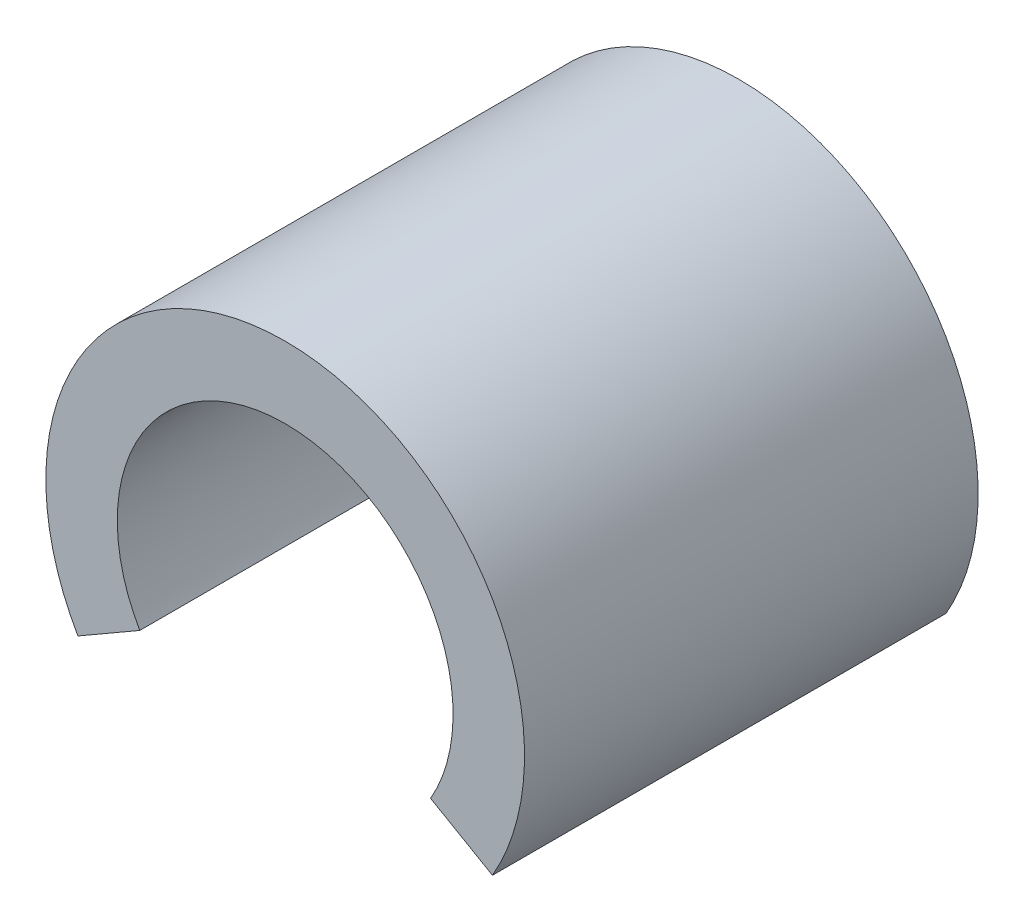
from build123d import *

# Parameters (mm, degrees)
BOSS_EXTRUDE1_DEPTH = 12.7


with BuildPart() as part:
    # Sketch1 → Boss-Extrude1 (new body)
    with BuildSketch(Plane.XY):
        with BuildLine():
            Line((-4.070319398, -2.35), (-5.802370205, -3.35))
            ThreePointArc((-5.802370205, -3.35), (0, 6.7), (5.802370205, -3.35))
            Line((5.802370205, -3.35), (4.070319398, -2.35))
            ThreePointArc((4.070319398, -2.35), (0, 4.7), (-4.070319398, -2.35))
        make_face()
    extrude(amount=BOSS_EXTRUDE1_DEPTH)


solid = part.part
